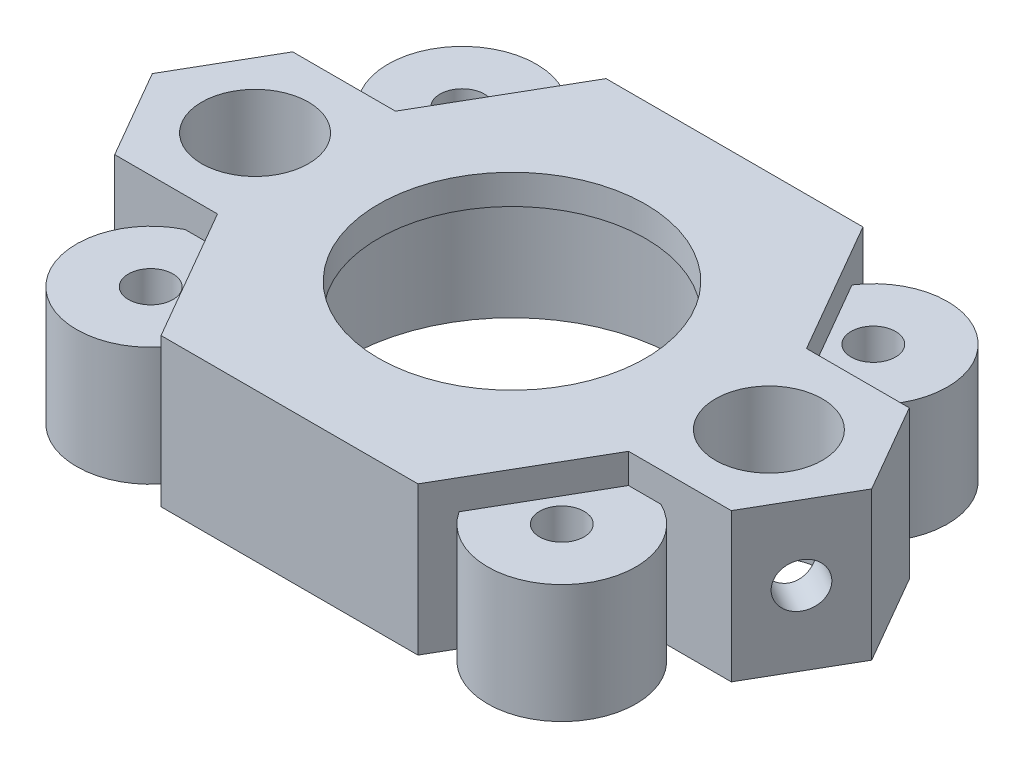
from build123d import *

# Parameters (mm, degrees)
SKETCH1_R                      = 11.125
SKETCH1_R_2                    = 3.6
SKETCH1_R_3                    = 1.5
BOSS_EXTRUDE1_DEPTH            = 8
SKETCH2_R                      = 9
SKETCH2_R_2                    = 3.6
BOSS_EXTRUDE2_DEPTH            = 2
CUT_EXTRUDE1_REACH             = 51.75
SKETCH4_R                      = 1.5
CUT_EXTRUDE1_DIRECTION_2_DEPTH = 8.75
CUT_EXTRUDE2_REACH             = 51.75
SKETCH5_R                      = 1.5


with BuildPart() as part:
    # Sketch1 → Boss-Extrude1 (new body)
    with BuildSketch(Plane(origin=(0, 0, 0), x_dir=(1, 0, 0), z_dir=(0, 1, 0))):
        with BuildLine():
            Line((8.660254038, 15), (-8.660254038, 15))
            Line((-8.660254038, 15), (-9.675277915, 13.241927075))
            ThreePointArc((-9.675277915, 13.241927075), (-17.613141308, 13.799536829), (-16.035855932, 6))
            Line((-16.035855932, 6), (-20.784609691, 6))
            Line((-20.784609691, 6), (-24.248711306, 0))
            Line((-24.248711306, 0), (-20.784609691, -6))
            Line((-20.784609691, -6), (-16.035855932, -6))
            ThreePointArc((-16.035855932, -6), (-17.613141308, -13.799536829), (-9.675277915, -13.241927075))
            Line((-9.675277915, -13.241927075), (-8.660254038, -15))
            Line((-8.660254038, -15), (8.660254038, -15))
            Line((8.660254038, -15), (9.675277915, -13.241927075))
            ThreePointArc((9.675277915, -13.241927075), (17.613141308, -13.799536829), (16.035855932, -6))
            Line((16.035855932, -6), (20.784609691, -6))
            Line((20.784609691, -6), (24.248711306, 0))
            Line((24.248711306, 0), (20.784609691, 6))
            Line((20.784609691, 6), (16.035855932, 6))
            ThreePointArc((16.035855932, 6), (17.613141308, 13.799536829), (9.675277915, 13.241927075))
            Line((9.675277915, 13.241927075), (8.660254038, 15))
        make_face()
        Circle(SKETCH1_R, mode=Mode.SUBTRACT)
        with Locations((17.320508076, 0)):
            Circle(SKETCH1_R_2, mode=Mode.SUBTRACT)
        with Locations((-17.320508076, 0)):
            Circle(SKETCH1_R_2, mode=Mode.SUBTRACT)
        with Locations((-13.856406461, 10.5)):
            Circle(SKETCH1_R_3, mode=Mode.SUBTRACT)
        with Locations((13.856406461, 10.5)):
            Circle(SKETCH1_R_3, mode=Mode.SUBTRACT)
        with Locations((13.856406461, -10.5)):
            Circle(SKETCH1_R_3, mode=Mode.SUBTRACT)
        with Locations((-13.856406461, -10.5)):
            Circle(SKETCH1_R_3, mode=Mode.SUBTRACT)
    extrude(amount=BOSS_EXTRUDE1_DEPTH)

    # Sketch2 → Boss-Extrude2 (add)
    with BuildSketch(Plane(origin=(0, 8, 0), x_dir=(1, 0, 0), z_dir=(0, 1, 0))):
        Polygon((8.660254038, -15), (13.856406461, -6), (20.784609691, -6), (24.248711306, 0), (20.784609691, 6), (13.856406461, 6), (8.660254038, 15), (-8.660254038, 15), (-13.856406461, 6), (-20.784609691, 6), (-24.248711306, 0), (-20.784609691, -6), (-13.856406461, -6), (-8.660254038, -15), align=None)
        Circle(SKETCH2_R, mode=Mode.SUBTRACT)
        with Locations((-17.320508076, 0)):
            Circle(SKETCH2_R_2, mode=Mode.SUBTRACT)
        with Locations((17.320508076, 0)):
            Circle(SKETCH2_R_2, mode=Mode.SUBTRACT)
    extrude(amount=BOSS_EXTRUDE2_DEPTH)

    # Sketch4 → Cut-Extrude1 (cut, up to next)
    with BuildSketch(Plane(origin=(-18.186533479, 0, 10.5), x_dir=(0.5, 0, 0.866025404), z_dir=(-0.866025404, 0, 0.5)), mode=Mode.PRIVATE) as cut_extrude1_sk1:
        with Locations((-8.660254038, 5)):
            Circle(SKETCH4_R)
    cut_extrude1_tool1 = extrude(cut_extrude1_sk1.sketch, amount=-CUT_EXTRUDE1_REACH, mode=Mode.PRIVATE) & part.part
    add(cut_extrude1_tool1.solids().sort_by_distance((-22.51666, 5, 3))[0], mode=Mode.SUBTRACT)

    # Sketch4 → Cut-Extrude1 direction 2 (cut)
    with BuildSketch(Plane(origin=(-18.186533479, 0, 10.5), x_dir=(0.5, 0, 0.866025404), z_dir=(-0.866025404, 0, 0.5))):
        with Locations((-8.660254038, 5)):
            Circle(SKETCH4_R)
    extrude(amount=CUT_EXTRUDE1_DIRECTION_2_DEPTH, mode=Mode.SUBTRACT)

    # Sketch5 → Cut-Extrude2 (cut, up to next)
    with BuildSketch(Plane(origin=(18.186533479, 0, 10.5), x_dir=(0.5, 0, -0.866025404), z_dir=(0.866025404, 0, 0.5)), mode=Mode.PRIVATE) as cut_extrude2_sk1:
        with Locations((8.660254038, 5)):
            Circle(SKETCH5_R)
    cut_extrude2_tool1 = extrude(cut_extrude2_sk1.sketch, amount=-CUT_EXTRUDE2_REACH, mode=Mode.PRIVATE) & part.part
    add(cut_extrude2_tool1.solids().sort_by_distance((22.51666, 5, 3))[0], mode=Mode.SUBTRACT)


solid = part.part
